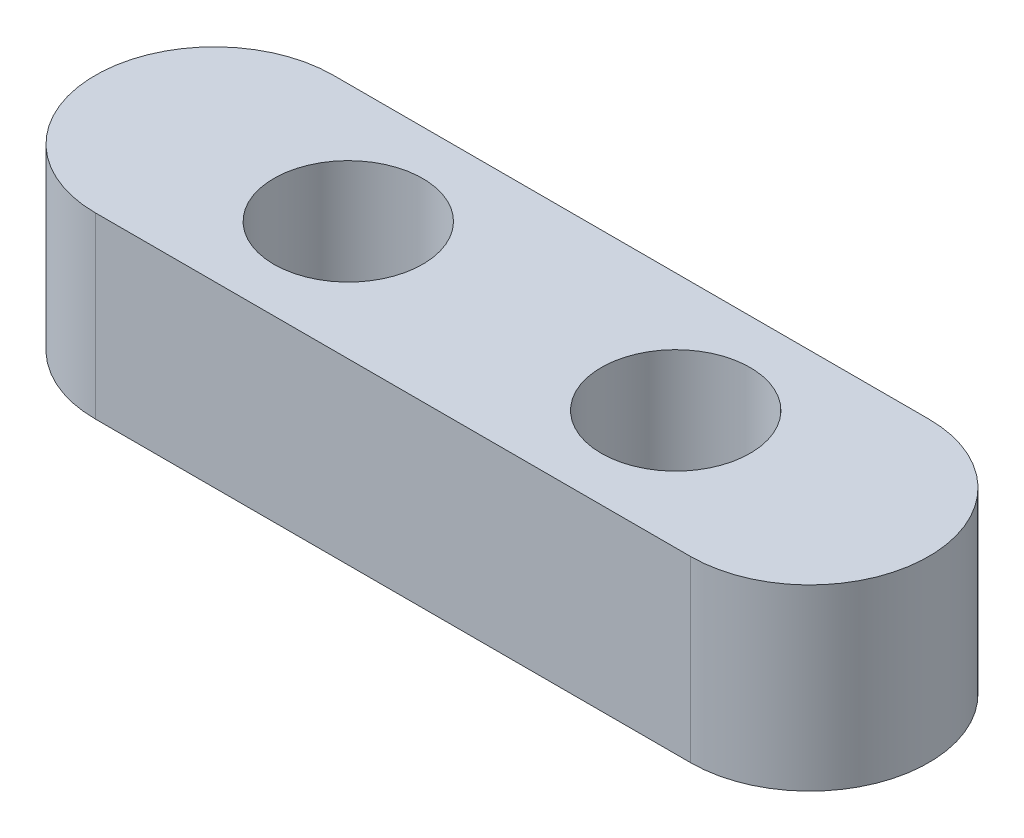
from build123d import *

# Parameters (mm, degrees)
SKETCH2_R           = 2.5
BOSS_EXTRUDE1_DEPTH = 6


with BuildPart() as part:
    # Sketch2 → Boss-Extrude1 (new body)
    with BuildSketch(Plane(origin=(0, 0, 0), x_dir=(1, 0, 0), z_dir=(0, 1, 0))):
        with BuildLine():
            Line((-10, 4), (10, 4))
            ThreePointArc((10, 4), (14, 0), (10, -4))
            Line((10, -4), (-10, -4))
            ThreePointArc((-10, -4), (-14, 0), (-10, 4))
        make_face()
        with Locations((-5.5, 0)):
            Circle(SKETCH2_R, mode=Mode.SUBTRACT)
        with Locations((5.5, 0)):
            Circle(SKETCH2_R, mode=Mode.SUBTRACT)
    extrude(amount=BOSS_EXTRUDE1_DEPTH)


solid = part.part
